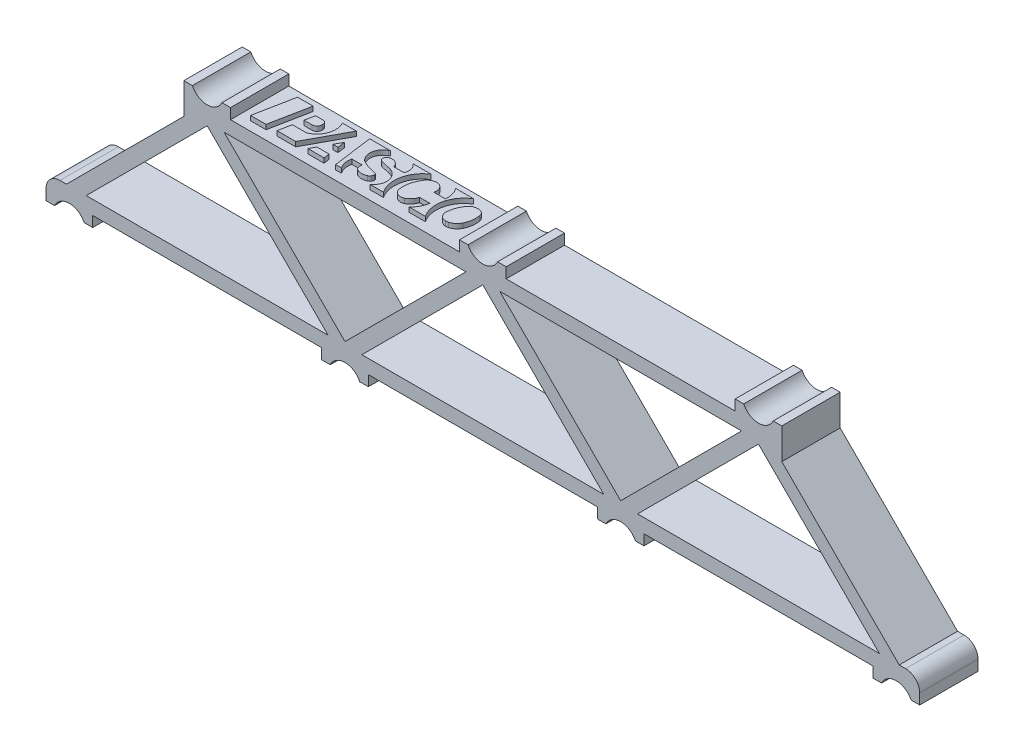
from build123d import *

# Parameters (mm, degrees)
BOSS_EXTRUDE1_DEPTH  = 3.175
BOSS_EXTRUDE2_DEPTH  = 3.175
BOSS_EXTRUDE3_START  = -3.175
BOSS_EXTRUDE3_DEPTH  = 6.35
FILLET1_R            = 1.524
FILLET1_OF_MIRROR1_R = 1.524
BOSS_EXTRUDE4_DEPTH  = 0.508


with BuildPart() as part:
    # Sketch1 → Boss-Extrude1 (new body, symmetric)
    with BuildSketch(Plane.XY):
        Polygon((-46.839630735, -15.762), (-30.315630735, 0.762), (0, 0.762), (30.315630735, 0.762), (46.839630735, -15.762), (15, -15.762), (-15, -15.762), align=None)
        Polygon((-43.160369265, -14.238), (-30, -1.077630735), (-16.839630735, -14.238), align=None, mode=Mode.SUBTRACT)
        Polygon((-28.160369265, -0.762), (-15, -13.922369265), (-1.839630735, -0.762), align=None, mode=Mode.SUBTRACT)
        Polygon((-13.160369265, -14.238), (0, -1.077630735), (13.160369265, -14.238), align=None, mode=Mode.SUBTRACT)
        Polygon((1.839630735, -0.762), (15, -13.922369265), (28.160369265, -0.762), align=None, mode=Mode.SUBTRACT)
        Polygon((16.839630735, -14.238), (30, -1.077630735), (43.160369265, -14.238), align=None, mode=Mode.SUBTRACT)
    extrude(amount=BOSS_EXTRUDE1_DEPTH, both=True)

    # Sketch2 → Boss-Extrude2 (add, symmetric)
    with BuildSketch(Plane.XY):
        with BuildLine():
            Line((-46.606437051, -16.905), (-47.54, -16.905))
            Line((-47.54, -16.905), (-47.54, -14.238))
            Line((-47.54, -14.238), (-42.46, -14.238))
            Line((-42.46, -14.238), (-42.46, -16.905))
            Line((-42.46, -16.905), (-43.393562949, -16.905))
            ThreePointArc((-43.393562949, -16.905), (-45, -15.889), (-46.606437051, -16.905))
        make_face()
        with BuildLine():
            Line((-27.46, 0.762), (-30.315630735, 0.762))
            Line((-30.315630735, 0.762), (-32.54, -1.462369265))
            Line((-32.54, -1.462369265), (-32.54, 0.762))
            Line((-32.54, 0.762), (-32.54, 1.905))
            Line((-32.54, 1.905), (-31.606437051, 1.905))
            ThreePointArc((-31.606437051, 1.905), (-30, 0.889), (-28.393562949, 1.905))
            Line((-28.393562949, 1.905), (-27.46, 1.905))
            Line((-27.46, 1.905), (-27.46, 0.762))
        make_face()
        with BuildLine():
            Line((-16.606437051, -16.905), (-17.54, -16.905))
            Line((-17.54, -16.905), (-17.54, -15.762))
            Line((-17.54, -15.762), (-12.46, -15.762))
            Line((-12.46, -15.762), (-12.46, -16.905))
            Line((-12.46, -16.905), (-13.393562949, -16.905))
            ThreePointArc((-13.393562949, -16.905), (-15, -15.889), (-16.606437051, -16.905))
        make_face()
    boss_extrude2 = extrude(amount=BOSS_EXTRUDE2_DEPTH, both=True)

    # Sketch3 → Boss-Extrude3 (add)
    with BuildSketch(Plane.XY.offset(BOSS_EXTRUDE3_START)):
        with BuildLine():
            Line((1.606437051, 1.905), (2.54, 1.905))
            Line((2.54, 1.905), (2.54, 0.762))
            Line((2.54, 0.762), (-2.54, 0.762))
            Line((-2.54, 0.762), (-2.54, 1.905))
            Line((-2.54, 1.905), (-1.606437051, 1.905))
            ThreePointArc((-1.606437051, 1.905), (0, 0.889), (1.606437051, 1.905))
        make_face()
    extrude(amount=BOSS_EXTRUDE3_DEPTH)

    # Fillet1
    fillet1_edges = [part.edges().sort_by_distance(p)[0] for p in [
        (-47.54, -14.238, 0),
    ]]
    fillet(fillet1_edges, radius=FILLET1_R)

    # Mirror1: Boss-Extrude2 across plane
    add(boss_extrude2.mirror(Plane(origin=(0, 0, 0), x_dir=(0, 0, 1), z_dir=(1, 0, 0))))

    # Fillet1 of Mirror1
    fillet1_of_mirror1_edges = [part.edges().sort_by_distance(p)[0] for p in [
        (47.54, -14.238, 0),
    ]]
    fillet(fillet1_of_mirror1_edges, radius=FILLET1_OF_MIRROR1_R)

    # Sketch4 → Boss-Extrude4 (add)
    with BuildSketch(Plane(origin=(30.341470111, 0.762, -10.998323426), x_dir=(-1, 0, 0), z_dir=(0, 1, 0))):
        Polygon((55.766638301, 8.903049935), (54.0821519, 8.903049935), (54.924395101, 13.184452869), (56.608881501, 13.184452869), align=None)
        with BuildLine():
            Line((49.373679321, 8.903049935), (51.695796166, 13.184452869))
            Line((51.695796166, 13.184452869), (53.731217234, 13.184452869))
            Line((53.731217234, 13.184452869), (53.455071922, 11.780714202))
            Line((53.455071922, 11.780714202), (52.044845481, 11.780714202))
            ThreePointArc((52.044845481, 11.780714202), (51.895660414, 11.763021636), (51.754751921, 11.710925494))
            ThreePointArc((51.754751921, 11.710925494), (50.74099205, 10.52746368), (50.853552966, 8.973236868))
            Line((50.853552966, 8.973236868), (50.888554794, 8.903049935))
            Line((50.888554794, 8.903049935), (49.373679321, 8.903049935))
        make_face()
        with BuildLine():
            Line((47.344206299, 13.184452869), (47.92473551, 8.903049935))
            Line((47.92473551, 8.903049935), (45.657455804, 8.903049935))
            Line((45.657455804, 8.903049935), (45.800093765, 8.973236868))
            ThreePointArc((45.800093765, 8.973236868), (46.559919921, 9.999679495), (46.16385217, 11.213784347))
            ThreePointArc((46.16385217, 11.213784347), (46.087708374, 11.278047887), (46.002485287, 11.329668676))
            ThreePointArc((46.002485287, 11.329668676), (45.241879319, 11.641820064), (44.44239948, 11.833632247))
            ThreePointArc((44.44239948, 11.833632247), (44.321830206, 11.897125178), (44.264573877, 12.020777977))
            ThreePointArc((44.264573877, 12.020777977), (44.273299822, 12.151811254), (44.326168164, 12.272022736))
            ThreePointArc((44.326168164, 12.272022736), (44.436687002, 12.409847066), (44.584321098, 12.50687352))
            ThreePointArc((44.584321098, 12.50687352), (45.07356558, 12.617554773), (45.566896159, 12.526805434))
            ThreePointArc((45.566896159, 12.526805434), (45.796502387, 12.340831934), (45.882880346, 12.05826511))
            Line((45.882880346, 12.05826511), (45.882880346, 11.780714202))
            Line((45.882880346, 11.780714202), (46.993271632, 11.780714202))
            ThreePointArc((46.993271632, 11.780714202), (47.00184458, 12.512372899), (46.712523898, 13.184452869))
            Line((46.712523898, 13.184452869), (47.344206299, 13.184452869))
        make_face()
        with BuildLine():
            Line((52.362572033, 10.727910202), (53.247962938, 10.727910202))
            Line((53.247962938, 10.727910202), (53.040853955, 9.675106202))
            Line((53.040853955, 9.675106202), (52.224130208, 9.675106202))
            ThreePointArc((52.224130208, 9.675106202), (51.949800938, 9.788737106), (51.836170033, 10.063066377))
            Line((51.836170033, 10.063066377), (51.836170033, 10.201508202))
            ThreePointArc((51.836170033, 10.201508202), (51.990349609, 10.573730626), (52.362572033, 10.727910202))
        make_face()
        Polygon((48.958505766, 10.596309702), (48.845492907, 11.429779536), (49.410557201, 11.429779536), align=None)
        Polygon((48.607571099, 13.184452869), (50.362244433, 13.184452869), (50.019637029, 12.552770469), (48.69322295, 12.552770469), align=None)
        with BuildLine():
            Line((43.093358174, 9.007864255), (43.203837606, 8.897384823))
            Line((43.203837606, 8.897384823), (41.238603472, 8.897384823))
            ThreePointArc((41.238603472, 8.897384823), (42.59037643, 10.850382179), (42.150373231, 13.184452869))
            Line((42.150373231, 13.184452869), (43.624298831, 13.184452869))
            ThreePointArc((43.624298831, 13.184452869), (42.976922737, 12.00046329), (43.609533036, 10.808518937))
            ThreePointArc((43.609533036, 10.808518937), (43.801404112, 10.703005905), (44.00849344, 10.63186155))
            Line((44.00849344, 10.63186155), (45.137184548, 10.349688773))
            ThreePointArc((45.137184548, 10.349688773), (45.325274084, 10.217067986), (45.375126192, 9.992388851))
            ThreePointArc((45.375126192, 9.992388851), (45.276758726, 9.771226443), (45.079326395, 9.631192719))
            ThreePointArc((45.079326395, 9.631192719), (44.392498989, 9.682709209), (43.976922089, 10.231964773))
            Line((43.976922089, 10.231964773), (42.853931155, 10.231964773))
            ThreePointArc((42.853931155, 10.231964773), (42.786913393, 9.583390951), (43.093358174, 9.007864255))
        make_face()
        with BuildLine():
            Line((38.57083963, 8.903049935), (36.605605496, 8.903049935))
            ThreePointArc((36.605605496, 8.903049935), (38.014670833, 10.833118693), (37.588222563, 13.184452869))
            Line((37.588222563, 13.184452869), (39.342895896, 13.184452869))
            ThreePointArc((39.342895896, 13.184452869), (38.831372076, 12.513225905), (38.57083963, 11.710527269))
            Line((38.57083963, 11.710527269), (39.693830563, 11.710527269))
            ThreePointArc((39.693830563, 11.710527269), (39.959617235, 12.233880985), (40.415270694, 12.603910164))
            ThreePointArc((40.415270694, 12.603910164), (41.166876497, 12.593701608), (41.591788981, 11.973649288))
            ThreePointArc((41.591788981, 11.973649288), (41.543037796, 10.949193829), (41.155213354, 9.999731945))
            ThreePointArc((41.155213354, 9.999731945), (40.782487914, 9.571566118), (40.251107207, 9.371854393))
            ThreePointArc((40.251107207, 9.371854393), (39.531077174, 9.674914925), (39.41308283, 10.447162469))
            Line((39.41308283, 10.447162469), (38.149718029, 10.447162469))
            ThreePointArc((38.149718029, 10.447162469), (38.201808334, 9.631886976), (38.57083963, 8.903049935))
        make_face()
        with BuildLine():
            Line((35.48104333, 9.602571887), (35.356873428, 9.602571887))
            ThreePointArc((35.356873428, 9.602571887), (34.923728887, 9.759646665), (34.691948891, 10.157848515))
            ThreePointArc((34.691948891, 10.157848515), (34.675735454, 10.986379145), (34.920455715, 11.778110082))
            ThreePointArc((34.920455715, 11.778110082), (35.261440878, 12.213116508), (35.747757566, 12.475790357))
            ThreePointArc((35.747757566, 12.475790357), (35.911443016, 12.505405638), (36.077655631, 12.511990293))
            ThreePointArc((36.077655631, 12.511990293), (36.647671195, 12.253324316), (36.864077445, 11.665962276))
            ThreePointArc((36.864077445, 11.665962276), (36.699639375, 10.801331502), (36.294750409, 10.019864179))
            ThreePointArc((36.294750409, 10.019864179), (35.938277424, 9.712977507), (35.48104333, 9.602571887))
        make_face()
    extrude(amount=BOSS_EXTRUDE4_DEPTH)


solid = part.part
